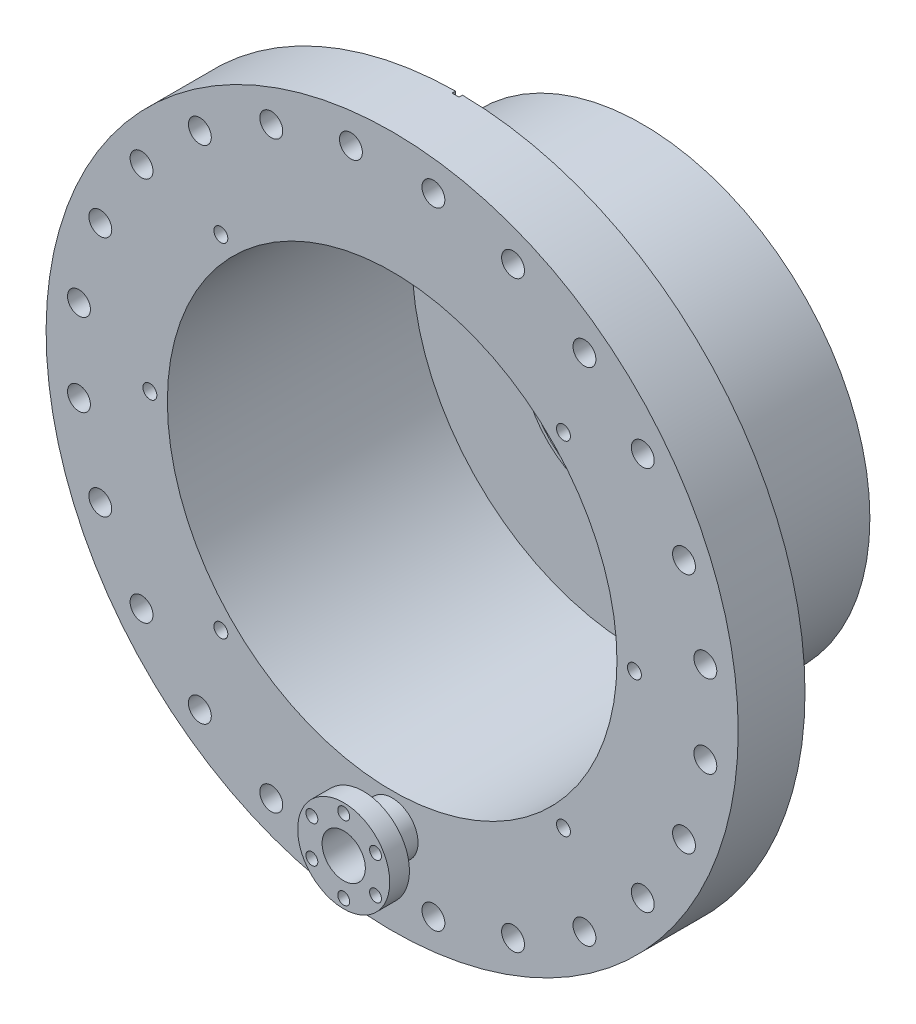
from build123d import *

# Parameters (mm, degrees)
SKETCH1_R                   = 83.5
SKETCH1_R_2                 = 82.5
EXTRUDE1_DEPTH              = 67.31
SKETCH2_R                   = 127
SKETCH2_R_2                 = 82.5
EXTRUDE2_DEPTH              = 24.511
SKETCH3_R                   = 4.2
CUT_EXTRUDE1_DEPTH          = 24.511
CIRPATTERN1_COUNT           = 24
SKETCH4_R                   = 83.5
SKETCH4_R_2                 = 32.2
EXTRUDE3_DEPTH              = 2
SKETCH13_R                  = 7.9375
EXTRUDE4_DEPTH              = 110.601
SKETCH14_R                  = 9.4996
SKETCH14_R_2                = 7.9375
EXTRUDE5_DEPTH              = 17.78
SKETCH15_R                  = 16.891
SKETCH15_R_2                = 7.9375
EXTRUDE6_DEPTH              = 7.239
SKETCH16_R                  = 2.1844
EXTRUDE7_DEPTH              = 7.239
CIRPATTERN2_COUNT           = 6
SKETCH17_W                  = 6.858832098
SKETCH17_H                  = 3.977015868
EXTRUDE8_DEPTH              = 7.62
MIRROR4_COPY_1_SKETCH_W     = 6.858832098
MIRROR4_COPY_1_SKETCH_H     = 3.977015868
MIRROR4_COPY_1_DEPTH        = 7.62
F_1_4_20_TAPPED_HOLE1_D     = 5.1054
F_1_4_20_TAPPED_HOLE1_DEPTH = 12.7
F_1_4_20_TAPPED_HOLE1_TIP   = 1.533816902
SKETCH21_W                  = 2.54
SKETCH21_H                  = 27.464757855
EXTRUDE9_DEPTH              = 1.27


with BuildPart() as part:
    # Sketch1 → Extrude1 (new body)
    with BuildSketch(Plane.XY):
        Circle(SKETCH1_R)
        Circle(SKETCH1_R_2, mode=Mode.SUBTRACT)
    extrude(amount=-EXTRUDE1_DEPTH)

    # Sketch2 → Extrude2 (add)
    with BuildSketch(Plane.XY):
        Circle(SKETCH2_R)
        Circle(SKETCH2_R_2, mode=Mode.SUBTRACT)
    extrude(amount=EXTRUDE2_DEPTH)

    # Sketch3 → Cut-Extrude1 (cut)
    with BuildSketch(Plane.XY.offset(24.511)):
        with Locations((15.131327149, -114.933840422)):
            Circle(SKETCH3_R)
    cut_extrude1 = extrude(amount=-CUT_EXTRUDE1_DEPTH, mode=Mode.SUBTRACT)

    # CirPattern1: Cut-Extrude1 ×24 about axis
    cirpattern1_axis = Axis((0, 0, 0), (0, 0, 1))
    for i in range(1, CIRPATTERN1_COUNT):
        add(cut_extrude1.rotate(cirpattern1_axis, i * 360 / CIRPATTERN1_COUNT), mode=Mode.SUBTRACT)

    # Sketch4 → Extrude3 (add)
    with BuildSketch(Plane(origin=(0, 0, -67.31), x_dir=(-1, 0, 0), z_dir=(0, 0, -1))):
        Circle(SKETCH4_R)
        Circle(SKETCH4_R_2, mode=Mode.SUBTRACT)
    extrude(amount=-EXTRUDE3_DEPTH)

    # Sketch5 → Revolve1 (revolve)
    with BuildSketch(Plane(origin=(0, 0, 0), x_dir=(1, 0, 0), z_dir=(0, 1, 0))):
        Polygon((-32.2, 67.31), (-32.2, 55.31), (-31, 55.31), (-31, 61.31), (-25, 67.31), align=None)
    revolve(axis=Axis((0, 0, 0), (0, 0, -1)))

    # Sketch11 → Cut-Revolve1 (revolve, cut)
    with BuildSketch(Plane(origin=(0, 0, 0), x_dir=(1, 0, 0), z_dir=(0, 1, 0))):
        Polygon((-31.7, 67.31), (-31.7, 61.317106781), (-25.707106781, 67.31), align=None)
    revolve(axis=Axis((0, 0, 0), (0, 0, -1)), mode=Mode.SUBTRACT)

    # Sketch13 → Extrude4 (cut, through all)
    with BuildSketch(Plane.XY.offset(42.291)):
        with Locations((0, -94.25)):
            Circle(SKETCH13_R)
    extrude(amount=-EXTRUDE4_DEPTH, mode=Mode.SUBTRACT)

    # Sketch14 → Extrude5 (add)
    with BuildSketch(Plane.XY.offset(42.291)):
        with Locations((0, -94.25)):
            Circle(SKETCH14_R)
        with Locations((0, -94.25)):
            Circle(SKETCH14_R_2, mode=Mode.SUBTRACT)
    extrude(amount=-EXTRUDE5_DEPTH)

    # Sketch15 → Extrude6 (add)
    with BuildSketch(Plane.XY.offset(42.291)):
        with Locations((0, -94.25)):
            Circle(SKETCH15_R)
        with Locations((0, -94.25)):
            Circle(SKETCH15_R_2, mode=Mode.SUBTRACT)
    extrude(amount=-EXTRUDE6_DEPTH)

    # Sketch16 → Extrude7 (cut)
    with BuildSketch(Plane.XY.offset(42.291)):
        with Locations((0, -80.7626)):
            Circle(SKETCH16_R)
    extrude7 = extrude(amount=-EXTRUDE7_DEPTH, mode=Mode.SUBTRACT)

    # CirPattern2: Extrude7 ×6 about axis
    cirpattern2_axis = Axis((0, -94.25, 0), (0, 0, 1))
    for i in range(1, CIRPATTERN2_COUNT):
        add(extrude7.rotate(cirpattern2_axis, i * 360 / CIRPATTERN2_COUNT), mode=Mode.SUBTRACT)

    # Sketch17 → Extrude8 (add)
    with BuildSketch(Plane(origin=(0, 0, -67.31), x_dir=(-1, 0, 0), z_dir=(0, 0, -1))):
        with Locations((-58, -26)):
            Rectangle(SKETCH17_W, SKETCH17_H)
    extrude8 = extrude(amount=EXTRUDE8_DEPTH)

    # Mirror3: Extrude8 across plane
    add(extrude8.mirror(Plane.ZX))

    # Mirror4: Extrude8 across plane
    add(extrude8.mirror(Plane(origin=(0, 0, 0), x_dir=(0, 0, 1), z_dir=(1, 0, 0))))

    # Mirror4 copy 1 sketch → Mirror4 copy 1 (add)
    with BuildSketch(Plane(origin=(0, 0, -67.31), x_dir=(1, 0, 0), z_dir=(0, 0, -1))):
        with Locations((-58, -26)):
            Rectangle(MIRROR4_COPY_1_SKETCH_W, MIRROR4_COPY_1_SKETCH_H)
    extrude(amount=MIRROR4_COPY_1_DEPTH)

    # 1/4-20 Tapped Hole1
    with Locations(Plane(origin=(62.861792847, -62.861792847, 24.511), x_dir=(1, 0, 0), z_dir=(0, 0, 1))):
        with Locations((0, 0), (-125.723585694, 0), (-151.761792847, 62.861792847), (-125.723585694, 125.723585694), (0, 125.723585694), (26.038207153, 62.861792847)):
            Hole(F_1_4_20_TAPPED_HOLE1_D / 2, depth=F_1_4_20_TAPPED_HOLE1_DEPTH)
            with Locations((0, 0, -(F_1_4_20_TAPPED_HOLE1_DEPTH + F_1_4_20_TAPPED_HOLE1_TIP / 2))):  # 118° drill point
                Cone(0, F_1_4_20_TAPPED_HOLE1_D / 2, F_1_4_20_TAPPED_HOLE1_TIP, mode=Mode.SUBTRACT)

    # Sketch21 → Extrude9 (cut)
    with BuildSketch(Plane(origin=(0, 0, 0), x_dir=(-1, 0, 0), z_dir=(0, 0, -1))):
        with Locations((0, -119.254869633)):
            Rectangle(SKETCH21_W, SKETCH21_H)
        with Locations((0, 119.254869633)):
            Rectangle(SKETCH21_W, SKETCH21_H)
    extrude(amount=-EXTRUDE9_DEPTH, mode=Mode.SUBTRACT)


solid = part.part
